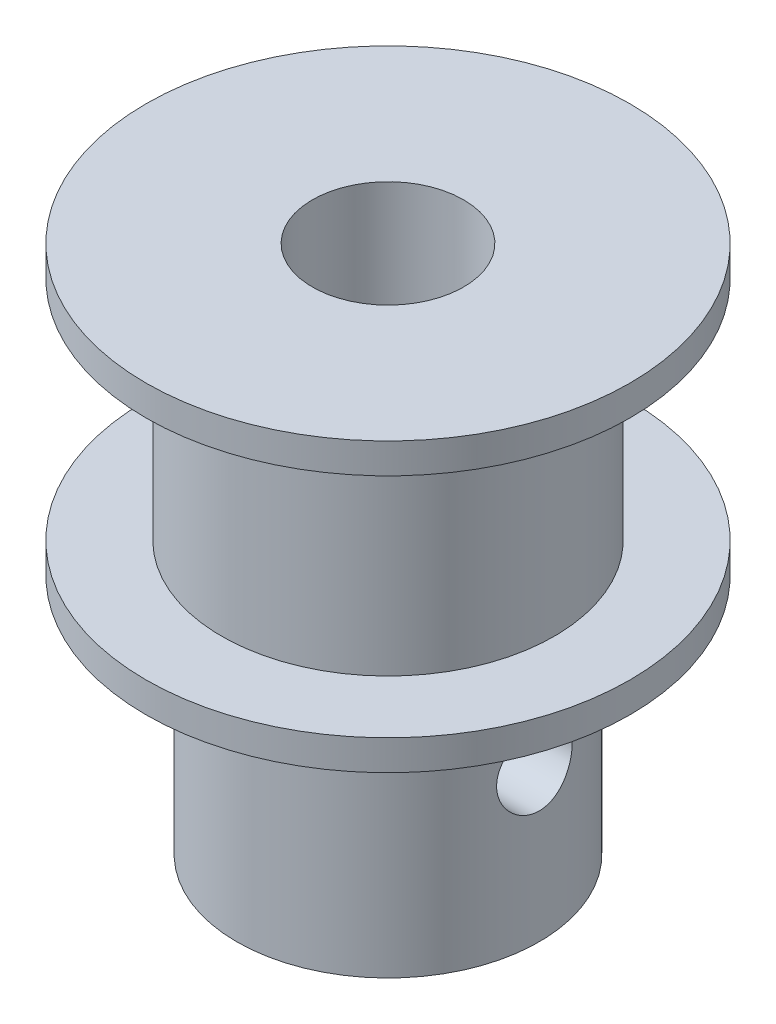
from build123d import *

# Parameters (mm, degrees)
CORTAR_EXTRUIR1_REACH      = 22.839
CORTAR_EXTRUIR1_END_RADIUS = 5
CROQUIS2_R                 = 1.25
MATRIZC1_COUNT             = 2
MATRIZC1_ANGLE             = 90


with BuildPart() as part:
    # Croquis1 → Revolución1 (revolve)
    with BuildSketch(Plane.XY, mode=Mode.PRIVATE) as revoluci_n1_sk:
        Polygon((8, 8), (5, 8), (5, 0), (2.5, 0), (2.5, 17.5), (8, 17.5), (8, 16.5), (5.5, 16.5), (5.5, 9), (8, 9), align=None)
    revolve(revoluci_n1_sk.sketch.rotate(Axis((0, 0, 0), (0, 1, 0)), 90), axis=Axis((0, 0, 0), (0, 1, 0)))

    # Cortar-Extruir1: up to this cylinder (the profile starts inside it)
    cortar_extruir1_end = Plane(origin=(0, 5, 0), z_dir=(0, -1, 0)) * Cylinder(CORTAR_EXTRUIR1_END_RADIUS, 56.678, mode=Mode.PRIVATE)
    # Croquis2 → Cortar-Extruir1 (cut, up to the surface)
    with BuildSketch(Plane.XY, mode=Mode.PRIVATE) as cortar_extruir1_sk1:
        with Locations((0, 5)):
            Circle(CROQUIS2_R)
    cortar_extruir1_tool1 = extrude(cortar_extruir1_sk1.sketch, amount=-CORTAR_EXTRUIR1_REACH, mode=Mode.PRIVATE) & cortar_extruir1_end
    cortar_extruir1 = cortar_extruir1_tool1.solids().sort_by_distance((0, 5, 0))[0]
    add(cortar_extruir1, mode=Mode.SUBTRACT)

    # MatrizC1: Cortar-Extruir1 ×2 about axis
    matrizc1_axis = Axis((0, 0, 0), (0, -1, 0))
    for i in range(1, MATRIZC1_COUNT):
        add(cortar_extruir1.rotate(matrizc1_axis, i * MATRIZC1_ANGLE / (MATRIZC1_COUNT - 1)), mode=Mode.SUBTRACT)


solid = part.part
